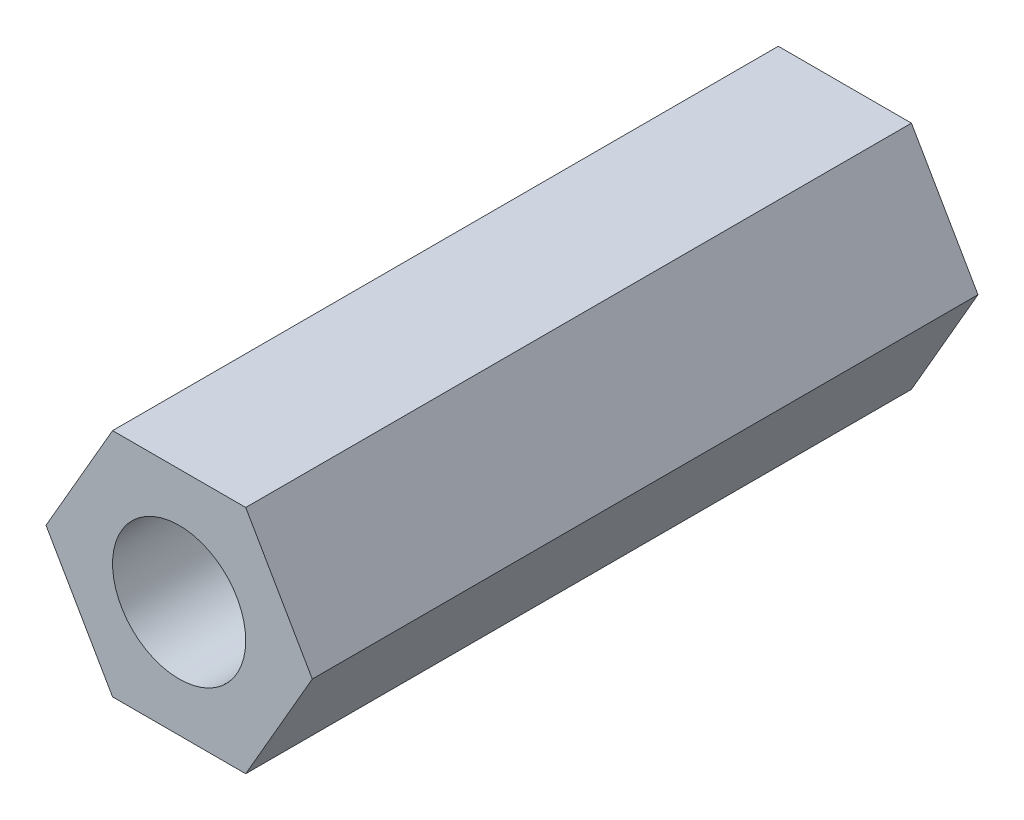
from build123d import *

# Parameters (mm, degrees)
CROQUIS1_R              = 1.5
SALIENTE_EXTRUIR1_DEPTH = 15


with BuildPart() as part:
    # Croquis1 → Saliente-Extruir1 (new body)
    with BuildSketch(Plane.XY):
        Polygon((1.500308251, 2.597898218), (-1.499691728, 2.598254168), (-2.999999979, 0.000355949), (-1.500308251, -2.597898218), (1.499691728, -2.598254168), (2.999999979, -0.000355949), align=None)
        Circle(CROQUIS1_R, mode=Mode.SUBTRACT)
    extrude(amount=SALIENTE_EXTRUIR1_DEPTH)


solid = part.part
